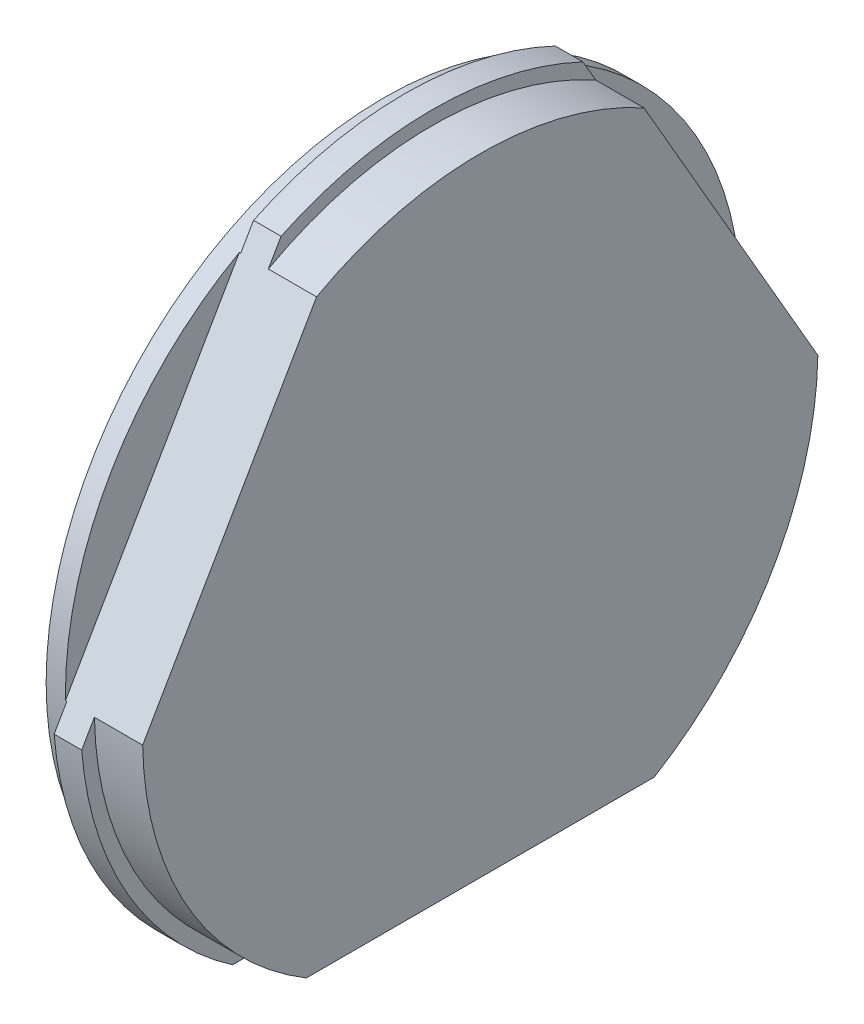
from build123d import *

# Parameters (mm, degrees)
CUT_EXTRUDE_1_DEPTH      = 4.5
CUT_EXTRUDE_1_DEPTH_BACK = 2.1


with BuildPart() as part:
    # Эскиз1 → Повернуть1 (revolve)
    with BuildSketch(Plane.XY):
        Polygon((-1.5, 24.5), (-1.5, 20), (4, 20), (4, 0), (5.5, 0), (5.5, 24.5), (2, 24.5), (2, 25.5), (0, 25.5), (0, 24.5), align=None)
    revolve(axis=Axis((-6.564956253, 0, 0), (1, 0, 0)))

    # Эскиз2 → Вырез-Вытянуть1 (cut, two sides)
    with BuildSketch(Plane(origin=(2, 0, 0), x_dir=(0, 0, -1), z_dir=(1, 0, 0))) as cut_extrude_1_sk:
        with BuildLine():
            ThreePointArc((-10.953795409, 23.027469816), (-22.083647797, 12.75), (-25.41927155, -2.027469816))
            Line((-25.41927155, -2.027469816), (-24.496248212, -0.428746497))
            ThreePointArc((-24.496248212, -0.428746497), (-21.217622393, 12.25), (-11.876818747, 21.428746497))
            Line((-11.876818747, 21.428746497), (-10.953795409, 23.027469816))
        make_face()
        with BuildLine():
            ThreePointArc((-11.876818747, 21.428746497), (-21.217622393, 12.25), (-24.496248212, -0.428746497))
            Line((-24.496248212, -0.428746497), (-11.876818747, 21.428746497))
        make_face()
        with BuildLine():
            Line((12.619429464, -21), (-12.619429464, -21))
            ThreePointArc((-12.619429464, -21), (0, -24.5), (12.619429464, -21))
        make_face()
        with BuildLine():
            Line((-12.619429464, -21), (-14.465476141, -21))
            ThreePointArc((-14.465476141, -21), (0, -25.5), (14.465476141, -21))
            Line((14.465476141, -21), (12.619429464, -21))
            ThreePointArc((12.619429464, -21), (0, -24.5), (-12.619429464, -21))
        make_face()
        with BuildLine():
            ThreePointArc((24.5, 0), (21.109619363, 12.435190804), (11.876818747, 21.428746497))
            Line((11.876818747, 21.428746497), (24.496248212, -0.428746497))
            ThreePointArc((24.496248212, -0.428746497), (24.499062035, -0.214381456), (24.5, 0))
        make_face()
        with BuildLine():
            ThreePointArc((25.5, 0), (21.558893558, 13.618520791), (10.953795409, 23.027469816))
            Line((10.953795409, 23.027469816), (11.876818747, 21.428746497))
            ThreePointArc((11.876818747, 21.428746497), (21.109619363, 12.435190804), (24.5, 0))
            ThreePointArc((24.5, 0), (24.499062035, -0.214381456), (24.496248212, -0.428746497))
            Line((24.496248212, -0.428746497), (25.41927155, -2.027469816))
            ThreePointArc((25.41927155, -2.027469816), (25.479809895, -1.014538188), (25.5, 0))
        make_face()
    extrude(amount=CUT_EXTRUDE_1_DEPTH, mode=Mode.SUBTRACT)
    extrude(cut_extrude_1_sk.sketch, amount=-CUT_EXTRUDE_1_DEPTH_BACK, mode=Mode.SUBTRACT)


solid = part.part
